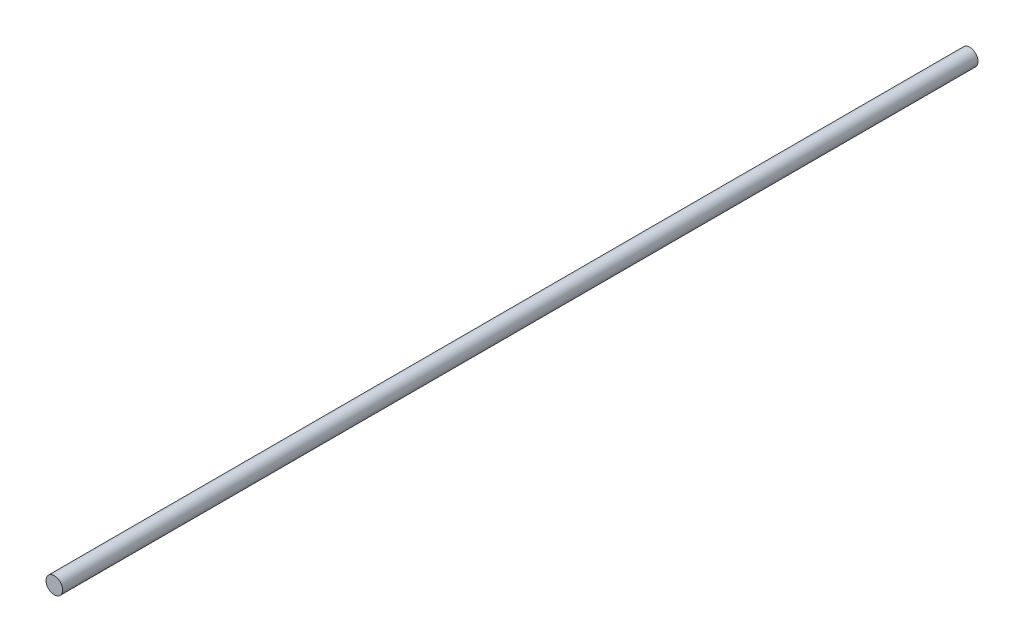
from build123d import *

# Parameters (mm, degrees)
ESQUISSE1_R        = 2.45
BOSS_EXTRU_1_DEPTH = 270


with BuildPart() as part:
    # Esquisse1 → Boss.-Extru.1 (new body)
    with BuildSketch(Plane.XY):
        Circle(ESQUISSE1_R)
    extrude(amount=BOSS_EXTRU_1_DEPTH)


solid = part.part
